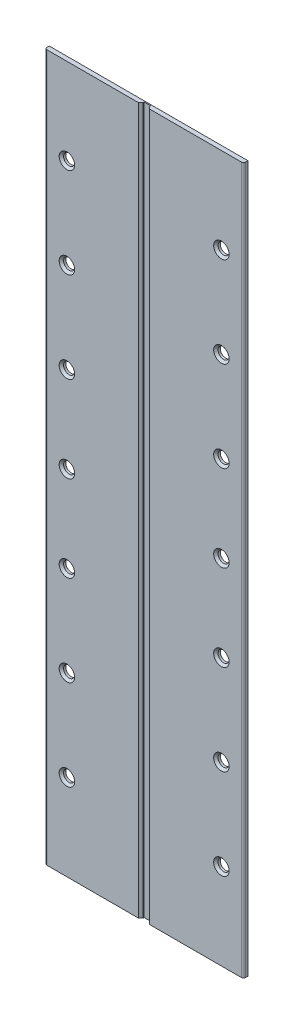
from build123d import *

# Parameters (mm, degrees)
ESQUISSE1_W             = 90
ESQUISSE1_H             = 320
BOSS_EXTRU_1_DEPTH      = 2
ESQUISSE2_R             = 2.5
ENL_V_MAT_EXTRU_1_DEPTH = 45
CONG_2_R                = 1
CHANFREIN1_SIZE         = 1
ENL_V_START             = 2
ESQUISSE3_W             = 3
ESQUISSE3_H             = 320
ENL_V_MAT_EXTRU_2_DEPTH = 1.5
CHANFREIN2_SIZE         = 1


with BuildPart() as part:
    # Esquisse1 → Boss.-Extru.1 (new body)
    with BuildSketch(Plane.XY):
        Rectangle(ESQUISSE1_W, ESQUISSE1_H)
    extrude(amount=BOSS_EXTRU_1_DEPTH)

    # Esquisse2 → Enlèv. mat.-Extru.1 (cut)
    with BuildSketch(Plane.XY.offset(2)):
        with Locations((-35, 120.982014683)):
            Circle(ESQUISSE2_R)
        with Locations((35, 120.982014683)):
            Circle(ESQUISSE2_R)
        with Locations((35, 80)):
            Circle(ESQUISSE2_R)
        with Locations((-35, 80)):
            Circle(ESQUISSE2_R)
        with Locations((-35, 39.017985317)):
            Circle(ESQUISSE2_R)
        with Locations((35, 39.017985317)):
            Circle(ESQUISSE2_R)
        with Locations((35, 0)):
            Circle(ESQUISSE2_R)
        with Locations((-35, 0)):
            Circle(ESQUISSE2_R)
        with Locations((-35, -39.017985317)):
            Circle(ESQUISSE2_R)
        with Locations((35, -39.017985317)):
            Circle(ESQUISSE2_R)
        with Locations((35, -80)):
            Circle(ESQUISSE2_R)
        with Locations((-35, -80)):
            Circle(ESQUISSE2_R)
        with Locations((35, -120.982014683)):
            Circle(ESQUISSE2_R)
        with Locations((-35, -120.982014683)):
            Circle(ESQUISSE2_R)
    extrude(amount=-ENL_V_MAT_EXTRU_1_DEPTH, mode=Mode.SUBTRACT)

    # Congé2
    cong_2_edges = [part.edges().sort_by_distance(p)[0] for p in [
        (45, 0, 2),
        (-45, 0, 2),
    ]]
    fillet(cong_2_edges, radius=CONG_2_R)

    # Chanfrein1
    chanfrein1_edges = [part.edges().sort_by_distance(p)[0] for p in [
        (-37.5, -39.017985317, 2),
        (-37.5, 0, 2),
        (32.5, 0, 2),
        (32.5, 39.017985317, 2),
        (-37.5, 39.017985317, 2),
        (-37.5, 80, 2),
        (32.5, 80, 2),
        (32.5, 120.982014683, 2),
        (-37.5, -120.982014683, 2),
        (32.5, -39.017985317, 2),
        (32.5, -80, 2),
        (-37.5, -80, 2),
        (32.5, -120.982014683, 2),
        (-37.5, 120.982014683, 2),
    ]]
    chamfer(chanfrein1_edges, length=CHANFREIN1_SIZE)

    # Esquisse3 → Enlèv. mat.-Extru.2 (cut)
    with BuildSketch(Plane.XY.offset(ENL_V_START)):
        Rectangle(ESQUISSE3_W, ESQUISSE3_H)
    extrude(amount=-ENL_V_MAT_EXTRU_2_DEPTH, mode=Mode.SUBTRACT)

    # Chanfrein2
    chanfrein2_edges = [part.edges().sort_by_distance(p)[0] for p in [
        (-1.5, 0, 2),
        (1.5, 0, 2),
    ]]
    chamfer(chanfrein2_edges, length=CHANFREIN2_SIZE)


solid = part.part
